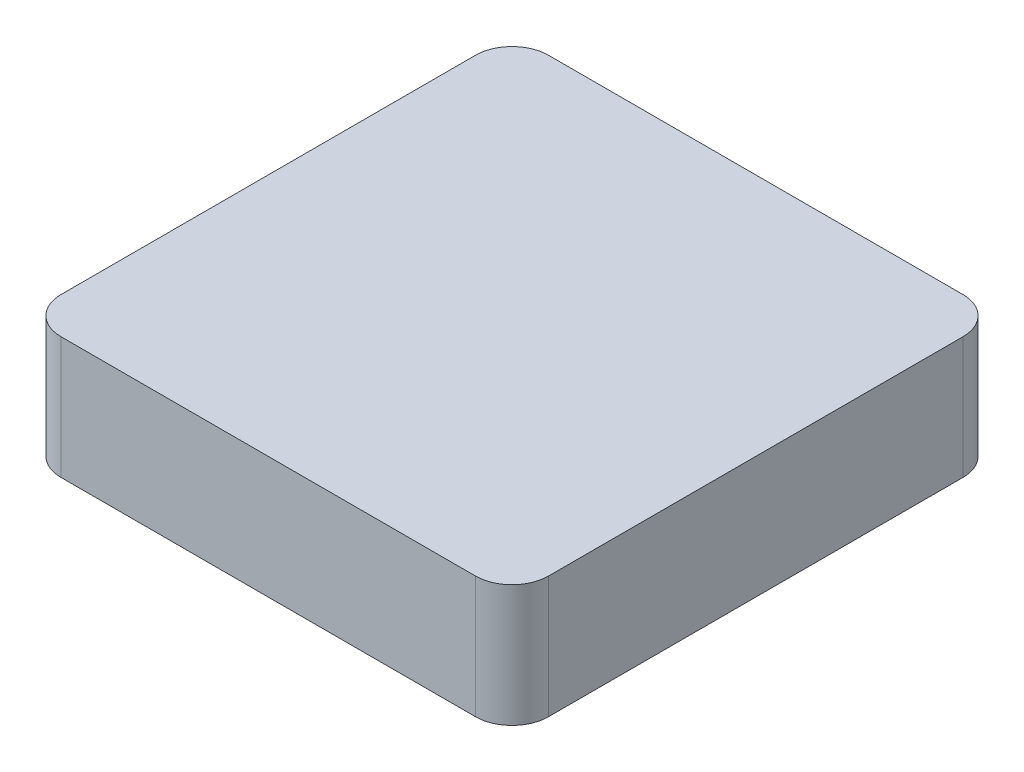
from build123d import *

# Parameters (mm, degrees)
BOSS_EXTRUDE1_DEPTH = 5


with BuildPart() as part:
    # Sketch1 → Boss-Extrude1 (new body)
    with BuildSketch(Plane(origin=(0, 0, 0), x_dir=(1, 0, 0), z_dir=(0, 1, 0))):
        with BuildLine():
            Line((-8.5, -10), (8.5, -10))
            ThreePointArc((8.5, -10), (9.560660172, -9.560660172), (10, -8.5))
            Line((10, -8.5), (10, 8.5))
            ThreePointArc((10, 8.5), (9.560660172, 9.560660172), (8.5, 10))
            Line((8.5, 10), (-8.5, 10))
            ThreePointArc((-8.5, 10), (-9.560660172, 9.560660172), (-10, 8.5))
            Line((-10, 8.5), (-10, -8.5))
            ThreePointArc((-10, -8.5), (-9.560660172, -9.560660172), (-8.5, -10))
        make_face()
    extrude(amount=BOSS_EXTRUDE1_DEPTH)


solid = part.part
